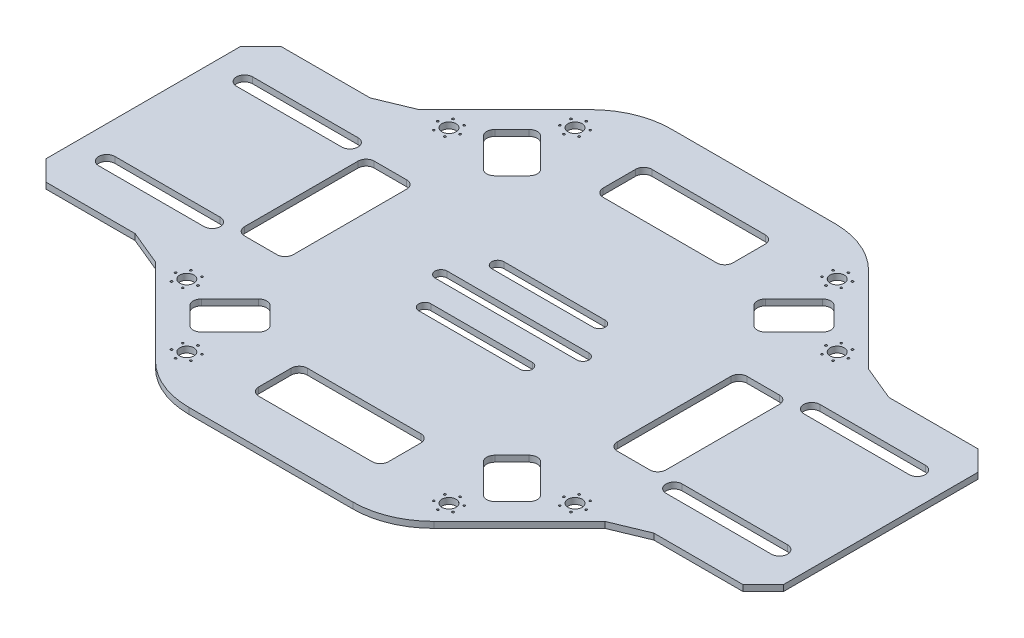
from build123d import *

# Parameters (mm, degrees)
BOSS_EXTRUDE1_DEPTH = 1.5
CHAMFER1_SIZE       = 5
FILLET1_R           = 20
CHAMFER2_SIZE       = 5
SKETCH3_R           = 1.75
CUT_EXTRUDE1_DEPTH  = 2.5
SKETCH4_W           = 32
SKETCH4_H           = 12
SKETCH4_W_2         = 12
SKETCH4_H_2         = 32
CUT_EXTRUDE2_DEPTH  = 1.5
FILLET2_R           = 2
CUT_EXTRUDE3_DEPTH  = 1.5
SKETCH6_R           = 0.25
CUT_EXTRUDE4_DEPTH  = 1.5


with BuildPart() as part:
    # Sketch1 → Boss-Extrude1 (new body)
    with BuildSketch(Plane(origin=(0, 0, 0), x_dir=(1, 0, 0), z_dir=(0, 1, 0))):
        Polygon((28.5, 59.5), (-28.5, 59.5), (-59, 29), (-91, 29), (-91, -29), (-59, -29), (-28.5, -59.5), (28.5, -59.5), (59, -29), (91, -29), (91, 29), (59, 29), align=None)
    extrude(amount=BOSS_EXTRUDE1_DEPTH)

    # Chamfer1
    chamfer1_edges = [part.edges().sort_by_distance(p)[0] for p in [
        (91, 0.75, -29),
        (91, 0.75, 29),
        (-91, 0.75, 29),
        (-91, 0.75, -29),
    ]]
    chamfer(chamfer1_edges, length=CHAMFER1_SIZE)

    # Fillet1
    fillet1_edges = [part.edges().sort_by_distance(p)[0] for p in [
        (-28.5, 0.75, -59.5),
        (28.5, 0.75, -59.5),
        (28.5, 0.75, 59.5),
        (-28.5, 0.75, 59.5),
    ]]
    fillet(fillet1_edges, radius=FILLET1_R)

    # Chamfer2
    chamfer2_edges = [part.edges().sort_by_distance(p)[0] for p in [
        (59, 0.75, -29),
        (59, 0.75, 29),
        (-59, 0.75, 29),
        (-59, 0.75, -29),
    ]]
    chamfer(chamfer2_edges, length=CHAMFER2_SIZE)

    # Sketch3 → Cut-Extrude1 (cut, through all)
    with BuildSketch(Plane(origin=(0, 1.5, 0), x_dir=(1, 0, 0), z_dir=(0, 1, 0))):
        with Locations(Location((-32.350135239, 47.906484425, 0), (0, 0, 270))):  # turned: the seam where the file's is
            Circle(SKETCH3_R)
        with Locations(Location((-47.906484425, 32.350135239, 0), (0, 0, 90))):  # turned: the seam where the file's is
            Circle(SKETCH3_R)
        with Locations(Location((32.350135239, 47.906484425, 0), (0, 0, 90))):  # turned: the seam where the file's is
            Circle(SKETCH3_R)
        with Locations(Location((47.906484425, 32.350135239, 0), (0, 0, 270))):  # turned: the seam where the file's is
            Circle(SKETCH3_R)
        with Locations(Location((47.906484425, -32.350135239, 0), (0, 0, 90))):  # turned: the seam where the file's is
            Circle(SKETCH3_R)
        with Locations(Location((32.350135239, -47.906484425, 0), (0, 0, 270))):  # turned: the seam where the file's is
            Circle(SKETCH3_R)
        with Locations(Location((-32.350135239, -47.906484425, 0), (0, 0, 90))):  # turned: the seam where the file's is
            Circle(SKETCH3_R)
        with Locations(Location((-47.906484425, -32.350135239, 0), (0, 0, 270))):  # turned: the seam where the file's is
            Circle(SKETCH3_R)
    extrude(amount=-CUT_EXTRUDE1_DEPTH, mode=Mode.SUBTRACT)

    # Sketch4 → Cut-Extrude2 (cut)
    with BuildSketch(Plane(origin=(0, 1.5, 0), x_dir=(1, 0, 0), z_dir=(0, 1, 0))):
        with BuildLine():
            Line((57, 19), (83, 19))
            ThreePointArc((83, 19), (85, 17), (83, 15))
            Line((83, 15), (57, 15))
            ThreePointArc((57, 15), (55, 17), (57, 19))
        make_face()
        with BuildLine():
            Line((-17.5, 1.5), (17.5, 1.5))
            ThreePointArc((17.5, 1.5), (19, 0), (17.5, -1.5))
            Line((17.5, -1.5), (-17.5, -1.5))
            ThreePointArc((-17.5, -1.5), (-19, 0), (-17.5, 1.5))
        make_face()
        with BuildLine():
            Line((-12.5, 10.5), (12.5, 10.5))
            ThreePointArc((12.5, 10.5), (14, 9), (12.5, 7.5))
            Line((12.5, 7.5), (-12.5, 7.5))
            ThreePointArc((-12.5, 7.5), (-14, 9), (-12.5, 10.5))
        make_face()
        with Locations((0, 42.5)):
            Rectangle(SKETCH4_W, SKETCH4_H)
        with Locations((46, 0)):
            Rectangle(SKETCH4_W_2, SKETCH4_H_2)
        with BuildLine():
            Line((57, -19), (83, -19))
            ThreePointArc((83, -19), (85, -17), (83, -15))
            Line((83, -15), (57, -15))
            ThreePointArc((57, -15), (55, -17), (57, -19))
        make_face()
        with BuildLine():
            Line((-12.5, -10.5), (12.5, -10.5))
            ThreePointArc((12.5, -10.5), (14, -9), (12.5, -7.5))
            Line((12.5, -7.5), (-12.5, -7.5))
            ThreePointArc((-12.5, -7.5), (-14, -9), (-12.5, -10.5))
        make_face()
        with Locations((-46, 0)):
            Rectangle(SKETCH4_W_2, SKETCH4_H_2)
        with BuildLine():
            Line((-57, -19), (-83, -19))
            ThreePointArc((-83, -19), (-85, -17), (-83, -15))
            Line((-83, -15), (-57, -15))
            ThreePointArc((-57, -15), (-55, -17), (-57, -19))
        make_face()
        with BuildLine():
            Line((-57, 19), (-83, 19))
            ThreePointArc((-83, 19), (-85, 17), (-83, 15))
            Line((-83, 15), (-57, 15))
            ThreePointArc((-57, 15), (-55, 17), (-57, 19))
        make_face()
        with Locations((0, -42.5)):
            Rectangle(SKETCH4_W, SKETCH4_H)
    extrude(amount=-CUT_EXTRUDE2_DEPTH, mode=Mode.SUBTRACT)

    # Fillet2
    fillet2_edges = [part.edges().sort_by_distance(p)[0] for p in [
        (-40, 0.75, -16),
        (-40, 0.75, 16),
        (-52, 0.75, 16),
        (-52, 0.75, -16),
        (-16, 0.75, -36.5),
        (-16, 0.75, -48.5),
        (16, 0.75, -48.5),
        (16, 0.75, -36.5),
        (40, 0.75, 16),
        (40, 0.75, -16),
        (52, 0.75, -16),
        (52, 0.75, 16),
        (16, 0.75, 48.5),
        (-16, 0.75, 48.5),
        (-16, 0.75, 36.5),
        (16, 0.75, 36.5),
    ]]
    fillet(fillet2_edges, radius=FILLET2_R)

    # Sketch5 → Cut-Extrude3 (cut)
    with BuildSketch(Plane(origin=(0, 1.5, 0), x_dir=(1, 0, 0), z_dir=(0, 1, 0))):
        with BuildLine():
            Line((-41.878679656, 37.636038969), (-37.636038969, 41.878679656))
            ThreePointArc((-37.636038969, 41.878679656), (-36.221825407, 42.464466094), (-34.807611845, 41.878679656))
            Line((-34.807611845, 41.878679656), (-27.736544033, 34.807611845))
            ThreePointArc((-27.736544033, 34.807611845), (-27.150757595, 33.393398282), (-27.736544033, 31.97918472))
            Line((-27.736544033, 31.97918472), (-31.97918472, 27.736544033))
            ThreePointArc((-31.97918472, 27.736544033), (-33.393398282, 27.150757595), (-34.807611845, 27.736544033))
            Line((-34.807611845, 27.736544033), (-41.878679656, 34.807611845))
            ThreePointArc((-41.878679656, 34.807611845), (-42.464466094, 36.221825407), (-41.878679656, 37.636038969))
        make_face()
        with BuildLine():
            Line((31.97918472, 27.736544033), (27.736544033, 31.97918472))
            ThreePointArc((27.736544033, 31.97918472), (27.150757595, 33.393398282), (27.736544033, 34.807611845))
            Line((27.736544033, 34.807611845), (34.807611845, 41.878679656))
            ThreePointArc((34.807611845, 41.878679656), (36.221825407, 42.464466094), (37.636038969, 41.878679656))
            Line((37.636038969, 41.878679656), (41.878679656, 37.636038969))
            ThreePointArc((41.878679656, 37.636038969), (42.464466094, 36.221825407), (41.878679656, 34.807611845))
            Line((41.878679656, 34.807611845), (34.807611845, 27.736544033))
            ThreePointArc((34.807611845, 27.736544033), (33.393398282, 27.150757595), (31.97918472, 27.736544033))
        make_face()
        with BuildLine():
            Line((27.736544033, -31.97918472), (31.97918472, -27.736544033))
            ThreePointArc((31.97918472, -27.736544033), (33.393398282, -27.150757595), (34.807611845, -27.736544033))
            Line((34.807611845, -27.736544033), (41.878679656, -34.807611845))
            ThreePointArc((41.878679656, -34.807611845), (42.464466094, -36.221825407), (41.878679656, -37.636038969))
            Line((41.878679656, -37.636038969), (37.636038969, -41.878679656))
            ThreePointArc((37.636038969, -41.878679656), (36.221825407, -42.464466094), (34.807611845, -41.878679656))
            Line((34.807611845, -41.878679656), (27.736544033, -34.807611845))
            ThreePointArc((27.736544033, -34.807611845), (27.150757595, -33.393398282), (27.736544033, -31.97918472))
        make_face()
        with BuildLine():
            Line((-31.97918472, -27.736544033), (-27.736544033, -31.97918472))
            ThreePointArc((-27.736544033, -31.97918472), (-27.150757595, -33.393398282), (-27.736544033, -34.807611845))
            Line((-27.736544033, -34.807611845), (-34.807611845, -41.878679656))
            ThreePointArc((-34.807611845, -41.878679656), (-36.221825407, -42.464466094), (-37.636038969, -41.878679656))
            Line((-37.636038969, -41.878679656), (-41.878679656, -37.636038969))
            ThreePointArc((-41.878679656, -37.636038969), (-42.464466094, -36.221825407), (-41.878679656, -34.807611845))
            Line((-41.878679656, -34.807611845), (-34.807611845, -27.736544033))
            ThreePointArc((-34.807611845, -27.736544033), (-33.393398282, -27.150757595), (-31.97918472, -27.736544033))
        make_face()
    extrude(amount=-CUT_EXTRUDE3_DEPTH, mode=Mode.SUBTRACT)

    # Sketch6 → Cut-Extrude4 (cut)
    with BuildSketch(Plane(origin=(0, 1.5, 0), x_dir=(1, 0, 0), z_dir=(0, 1, 0))):
        with Locations(Location((-32.350135239, 50.656484425, 0), (0, 0, 270))):  # turned: the seam where the file's is
            Circle(SKETCH6_R)
        with Locations(Location((-29.968565379, 49.281484425, 0), (0, 0, 270))):  # turned: the seam where the file's is
            Circle(SKETCH6_R)
        with Locations(Location((-29.968565379, 46.531484425, 0), (0, 0, 270))):  # turned: the seam where the file's is
            Circle(SKETCH6_R)
        with Locations(Location((-32.350135239, 45.156484425, 0), (0, 0, 270))):  # turned: the seam where the file's is
            Circle(SKETCH6_R)
        with Locations(Location((-34.7317051, 46.531484425, 0), (0, 0, 270))):  # turned: the seam where the file's is
            Circle(SKETCH6_R)
        with Locations(Location((-34.7317051, 49.281484425, 0), (0, 0, 270))):  # turned: the seam where the file's is
            Circle(SKETCH6_R)
        with Locations(Location((-49.281484425, 34.7317051, 0), (0, 0, 90))):  # turned: the seam where the file's is
            Circle(SKETCH6_R)
        with Locations(Location((-46.531484425, 34.7317051, 0), (0, 0, 90))):  # turned: the seam where the file's is
            Circle(SKETCH6_R)
        with Locations(Location((-45.156484425, 32.350135239, 0), (0, 0, 90))):  # turned: the seam where the file's is
            Circle(SKETCH6_R)
        with Locations(Location((-46.531484425, 29.968565379, 0), (0, 0, 90))):  # turned: the seam where the file's is
            Circle(SKETCH6_R)
        with Locations(Location((-49.281484425, 29.968565379, 0), (0, 0, 90))):  # turned: the seam where the file's is
            Circle(SKETCH6_R)
        with Locations(Location((-50.656484425, 32.350135239, 0), (0, 0, 90))):  # turned: the seam where the file's is
            Circle(SKETCH6_R)
        with Locations(Location((-50.656484425, -32.350135239, 0), (0, 0, 270))):  # turned: the seam where the file's is
            Circle(SKETCH6_R)
        with Locations(Location((-49.281484425, -29.968565379, 0), (0, 0, 270))):  # turned: the seam where the file's is
            Circle(SKETCH6_R)
        with Locations(Location((-46.531484425, -29.968565379, 0), (0, 0, 270))):  # turned: the seam where the file's is
            Circle(SKETCH6_R)
        with Locations(Location((-45.156484425, -32.350135239, 0), (0, 0, 270))):  # turned: the seam where the file's is
            Circle(SKETCH6_R)
        with Locations(Location((-46.531484425, -34.7317051, 0), (0, 0, 270))):  # turned: the seam where the file's is
            Circle(SKETCH6_R)
        with Locations(Location((-49.281484425, -34.7317051, 0), (0, 0, 270))):  # turned: the seam where the file's is
            Circle(SKETCH6_R)
        with Locations(Location((-34.7317051, -46.531484425, 0), (0, 0, 90))):  # turned: the seam where the file's is
            Circle(SKETCH6_R)
        with Locations(Location((-32.350135239, -45.156484425, 0), (0, 0, 90))):  # turned: the seam where the file's is
            Circle(SKETCH6_R)
        with Locations(Location((-29.968565379, -46.531484425, 0), (0, 0, 90))):  # turned: the seam where the file's is
            Circle(SKETCH6_R)
        with Locations(Location((-29.968565379, -49.281484425, 0), (0, 0, 90))):  # turned: the seam where the file's is
            Circle(SKETCH6_R)
        with Locations(Location((-32.350135239, -50.656484425, 0), (0, 0, 90))):  # turned: the seam where the file's is
            Circle(SKETCH6_R)
        with Locations(Location((-34.7317051, -49.281484425, 0), (0, 0, 90))):  # turned: the seam where the file's is
            Circle(SKETCH6_R)
        with Locations(Location((32.350135239, -50.656484425, 0), (0, 0, 270))):  # turned: the seam where the file's is
            Circle(SKETCH6_R)
        with Locations(Location((29.968565379, -49.281484425, 0), (0, 0, 270))):  # turned: the seam where the file's is
            Circle(SKETCH6_R)
        with Locations(Location((29.968565379, -46.531484425, 0), (0, 0, 270))):  # turned: the seam where the file's is
            Circle(SKETCH6_R)
        with Locations(Location((32.350135239, -45.156484425, 0), (0, 0, 270))):  # turned: the seam where the file's is
            Circle(SKETCH6_R)
        with Locations(Location((34.7317051, -46.531484425, 0), (0, 0, 270))):  # turned: the seam where the file's is
            Circle(SKETCH6_R)
        with Locations(Location((34.7317051, -49.281484425, 0), (0, 0, 270))):  # turned: the seam where the file's is
            Circle(SKETCH6_R)
        with Locations(Location((46.531484425, -34.7317051, 0), (0, 0, 90))):  # turned: the seam where the file's is
            Circle(SKETCH6_R)
        with Locations(Location((45.156484425, -32.350135239, 0), (0, 0, 90))):  # turned: the seam where the file's is
            Circle(SKETCH6_R)
        with Locations(Location((46.531484425, -29.968565379, 0), (0, 0, 90))):  # turned: the seam where the file's is
            Circle(SKETCH6_R)
        with Locations(Location((49.281484425, -29.968565379, 0), (0, 0, 90))):  # turned: the seam where the file's is
            Circle(SKETCH6_R)
        with Locations(Location((50.656484425, -32.350135239, 0), (0, 0, 90))):  # turned: the seam where the file's is
            Circle(SKETCH6_R)
        with Locations(Location((49.281484425, -34.7317051, 0), (0, 0, 90))):  # turned: the seam where the file's is
            Circle(SKETCH6_R)
        with Locations(Location((50.656484425, 32.350135239, 0), (0, 0, 270))):  # turned: the seam where the file's is
            Circle(SKETCH6_R)
        with Locations(Location((49.281484425, 29.968565379, 0), (0, 0, 270))):  # turned: the seam where the file's is
            Circle(SKETCH6_R)
        with Locations(Location((46.531484425, 29.968565379, 0), (0, 0, 270))):  # turned: the seam where the file's is
            Circle(SKETCH6_R)
        with Locations(Location((45.156484425, 32.350135239, 0), (0, 0, 270))):  # turned: the seam where the file's is
            Circle(SKETCH6_R)
        with Locations(Location((46.531484425, 34.7317051, 0), (0, 0, 270))):  # turned: the seam where the file's is
            Circle(SKETCH6_R)
        with Locations(Location((49.281484425, 34.7317051, 0), (0, 0, 270))):  # turned: the seam where the file's is
            Circle(SKETCH6_R)
        with Locations(Location((34.7317051, 46.531484425, 0), (0, 0, 90))):  # turned: the seam where the file's is
            Circle(SKETCH6_R)
        with Locations(Location((32.350135239, 45.156484425, 0), (0, 0, 90))):  # turned: the seam where the file's is
            Circle(SKETCH6_R)
        with Locations(Location((29.968565379, 46.531484425, 0), (0, 0, 90))):  # turned: the seam where the file's is
            Circle(SKETCH6_R)
        with Locations(Location((29.968565379, 49.281484425, 0), (0, 0, 90))):  # turned: the seam where the file's is
            Circle(SKETCH6_R)
        with Locations(Location((32.350135239, 50.656484425, 0), (0, 0, 90))):  # turned: the seam where the file's is
            Circle(SKETCH6_R)
        with Locations(Location((34.7317051, 49.281484425, 0), (0, 0, 90))):  # turned: the seam where the file's is
            Circle(SKETCH6_R)
    extrude(amount=-CUT_EXTRUDE4_DEPTH, mode=Mode.SUBTRACT)


solid = part.part
